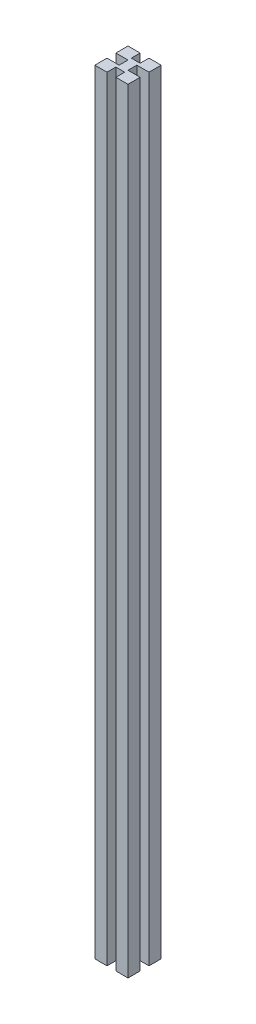
from build123d import *

# Parameters (mm, degrees)
BOSS_EXTRUDE1_DEPTH = 700


with BuildPart() as part:
    # Sketch1 → Boss-Extrude1 (new body)
    with BuildSketch(Plane(origin=(0, 0, 0), x_dir=(1, 0, 0), z_dir=(0, 1, 0))):
        Polygon((-11, 3), (-11, -8), (0, -8), (0, 0), (8, 0), (8, -8), (19, -8), (19, 3), (8, 3), (8, 11), (19, 11), (19, 22), (8, 22), (8, 14), (0, 14), (0, 22), (-11, 22), (-11, 11), (0, 11), (0, 3), align=None)
    extrude(amount=BOSS_EXTRUDE1_DEPTH)


solid = part.part
